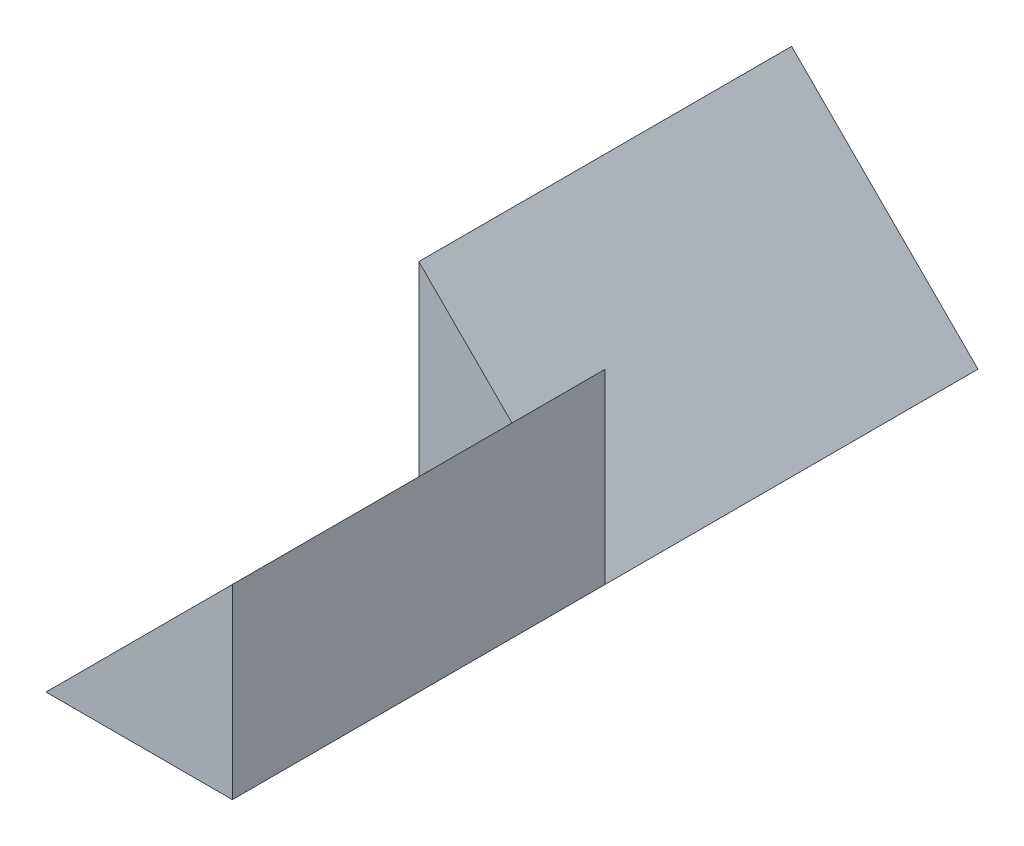
from build123d import *

# Parameters (mm, degrees)
BOSS_EXTRUDE1_DEPTH = 2
BOSS_EXTRUDE2_DEPTH = 2


with BuildPart() as part:
    # Sketch1 → Boss-Extrude1 (new body)
    with BuildSketch(Plane.XY):
        Polygon((0, 0), (0, 1), (1, 0), align=None)
    extrude(amount=BOSS_EXTRUDE1_DEPTH)

    # Sketch2 → Boss-Extrude2 (add)
    with BuildSketch(Plane.XY.offset(2)):
        Polygon((1, 0), (1, 1), (0, 0), align=None)
    extrude(amount=BOSS_EXTRUDE2_DEPTH)


solid = part.part
